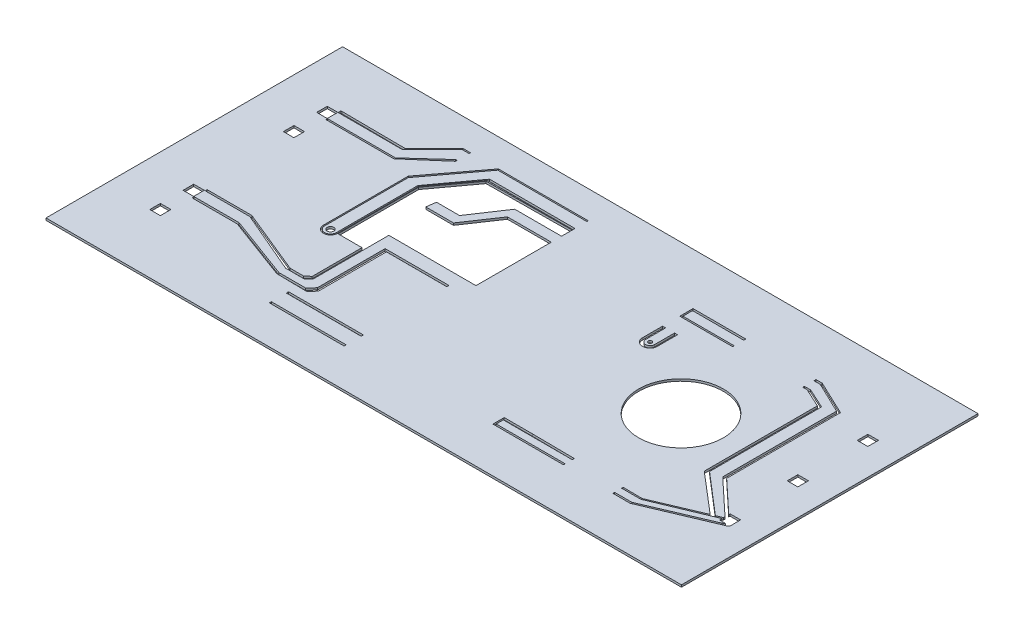
from build123d import *

# Parameters (mm, degrees)
SKETCH1_W           = 30
SKETCH1_H           = 14
SKETCH1_R           = 2
SKETCH1_R_2         = 0.156028334
SKETCH1_R_3         = 0.086225259
SKETCH1_W_2         = 0.499197809
SKETCH1_H_2         = 0.501456342
SKETCH1_H_3         = 0.501456343
SKETCH1_W_3         = 3.5304532
SKETCH1_H_4         = 0.096477131
BOSS_EXTRUDE2_DEPTH = 0.1


with BuildPart() as part:
    # Sketch1 → Boss-Extrude2 (new body)
    with BuildSketch(Plane(origin=(0, 0, 0), x_dir=(1, 0, 0), z_dir=(0, 1, 0))):
        with Locations((-15, 7)):
            Rectangle(SKETCH1_W, SKETCH1_H)
        with Locations((-7.020370045, 7)):
            Circle(SKETCH1_R, mode=Mode.SUBTRACT)
        with Locations((-22.822406344, 6.255391347)):
            Circle(SKETCH1_R_2, mode=Mode.SUBTRACT)
        with Locations((-10.66724947, 9.187062819)):
            Circle(SKETCH1_R_3, mode=Mode.SUBTRACT)
        with Locations((-1.506295526, 10.305773891)):
            Rectangle(SKETCH1_W_2, SKETCH1_H_2, mode=Mode.SUBTRACT)
        with Locations((-1.506058557, 7)):
            Rectangle(SKETCH1_W_2, SKETCH1_H_2, mode=Mode.SUBTRACT)
        Polygon((-1.256485692, 3.550454026), (-1.28140444, 3.550454026), (-1.335016171, 3.481213999), (-4.54690164, 2.121887432), (-5.360261371, 2.121887432), (-5.360261371, 2.203832458), (-4.54690164, 2.203832458), (-1.558352374, 3.481213999), (-1.472133003, 3.550454026), (-1.755683501, 3.550454026), (-1.755683501, 3.663429203), (-1.781688576, 3.652423397), (-4.453252976, 2.537894228), (-5.360261371, 2.537894228), (-5.360261371, 2.611390791), (-4.453252976, 2.602147786), (-2.199910697, 3.555801973), (-2.230986224, 3.58233105), (-4.109880419, 5.186336967), (-4.109880419, 10.52625285), (-5.01178132, 10.9436629), (-5.2151716, 10.9436629), (-5.2151716, 11.019115731), (-4.92219693, 11.019115731), (-3.967960979, 10.583630365), (-3.967960979, 5.294234739), (-2.054874003, 3.652423397), (-2.027101226, 3.628937988), (-1.781688576, 3.732800949), (-1.755683501, 3.743806755), (-1.755683501, 3.811781185), (-1.824138086, 3.875872934), (-3.440230513, 5.388966468), (-3.440230513, 10.76142511), (-4.92219693, 11.471832711), (-5.2151716, 11.471832711), (-5.2151716, 11.567863586), (-4.92219693, 11.567863586), (-3.286271687, 10.793793894), (-3.286271687, 5.420857378), (-1.824138086, 4.051910368), (-1.755683501, 3.987818619), (-1.755683501, 4.051910368), (-1.256485692, 4.051910368), align=None, mode=Mode.SUBTRACT)
        Polygon((-20.740691313, 3.555801973), (-20.740691313, 6.751171354), (-17.726140192, 6.751171354), (-17.726140192, 6.648804669), (-20.577135817, 6.648804669), (-20.577135817, 6.588691856), (-20.577135817, 3.434422851), (-20.839350262, 3.147232695), (-22.275377127, 3.170945708), (-25.245108692, 4.270018773), (-27.280489968, 4.270018773), (-27.371609442, 4.270018773), (-27.371609442, 4.36632395), (-27.280489968, 4.36632395), (-25.245108692, 4.36632395), (-22.268787234, 3.26481202), (-21.006375102, 3.26481202), align=None, mode=Mode.SUBTRACT)
        Polygon((-21.196743275, 7.250728171), (-21.196743275, 4.159991696), (-21.196743275, 3.801090583), (-21.398034662, 3.601705999), (-22.289698939, 3.601705999), (-25.245108692, 4.867780292), (-27.280489968, 4.867780292), (-27.350305288, 4.867780292), (-27.350305288, 4.960770533), (-27.280489968, 4.960770533), (-25.245108692, 4.960770533), (-22.177931991, 3.706985367), (-21.552803523, 3.706985367), (-21.32716444, 3.895195799), (-21.32716444, 6.24470924), (-22.461941115, 6.24470924), (-22.461941115, 10.05504572), (-21.11708673, 11.889354862), (-17.082611668, 11.926021935), (-17.082611668, 11.511053117), (-17.082611668, 11.422021861), (-17.122361985, 11.422021861), (-19.29309074, 11.422021861), (-20.335207519, 9.860770298), (-21.423827816, 9.860770298), (-21.486437697, 9.415587946), (-20.176259884, 9.415587946), (-19.152866511, 10.937472578), (-17.122361985, 10.937472578), (-17.082611668, 10.937472578), (-17.082611668, 10.879889975), (-17.082611668, 7.382432578), (-17.726140192, 7.382432578), (-20.577135817, 7.382432578), (-21.196743275, 7.382432578), align=None, mode=Mode.SUBTRACT)
        with Locations((-27.644321584, 3.044426332)):
            Rectangle(SKETCH1_W_2, SKETCH1_H_3, mode=Mode.SUBTRACT)
        with Locations((-27.644321584, 4.617052121)):
            Rectangle(SKETCH1_W_2, SKETCH1_H_2, mode=Mode.SUBTRACT)
        with Locations((-27.677861275, 9.382947879)):
            Rectangle(SKETCH1_W_2, SKETCH1_H_2, mode=Mode.SUBTRACT)
        with Locations((-27.677861275, 10.955573669)):
            Rectangle(SKETCH1_W_2, SKETCH1_H_3, mode=Mode.SUBTRACT)
        Polygon((-27.350305288, 11.20630184), (-24.391373084, 11.20630184), (-22.978434678, 12.619240246), (-22.649427056, 12.619240246), (-22.649427056, 12.684571648), (-23.000461853, 12.684571648), (-24.206065105, 11.478968396), (-24.365525074, 11.319508427), (-27.350305288, 11.342635118), (-27.41709617, 11.342635118), (-27.41709617, 11.20630184), align=None, mode=Mode.SUBTRACT)
        Polygon((-22.649427056, 12.055976166), (-22.721193305, 12.055976166), (-24.207502155, 10.704845497), (-27.350305288, 10.704845497), (-27.41709617, 10.704845497), (-27.41709617, 10.628998487), (-27.350305288, 10.628998487), (-24.207502155, 10.628998487), (-22.687589847, 11.947769263), (-22.649427056, 11.947769263), align=None, mode=Mode.SUBTRACT)
        Polygon((-21.256593392, 2.708605309), (-20.577135817, 2.708605309), (-17.726140192, 2.708605309), (-17.726140192, 2.602147786), (-20.577135817, 2.602147786), (-21.256593392, 2.602147786), align=None, mode=Mode.SUBTRACT)
        with Locations((-19.491366792, 1.848628129)):
            Rectangle(SKETCH1_W_3, SKETCH1_H_4, mode=Mode.SUBTRACT)
        with BuildLine():
            Line((-22.547722421, 9.635418098), (-22.547722421, 6.231004531))
            ThreePointArc((-22.547722421, 6.231004531), (-22.834611713, 5.979897239), (-23.09817069, 6.255391347))
            Line((-23.09817069, 6.255391347), (-23.09817069, 9.635418098))
            Line((-23.09817069, 9.635418098), (-23.09817069, 10.19716986))
            Line((-23.09817069, 10.19716986), (-21.285526409, 12.619240246))
            Line((-21.285526409, 12.619240246), (-17.082611668, 12.619240246))
            Line((-17.082611668, 12.619240246), (-17.082611668, 12.684571648))
            Line((-17.082611668, 12.684571648), (-21.32716444, 12.684571648))
            Line((-21.32716444, 12.684571648), (-23.158169226, 10.26019319))
            Line((-23.158169226, 10.26019319), (-23.158169226, 9.635418098))
            Line((-23.158169226, 9.635418098), (-23.158169226, 6.255391347))
            ThreePointArc((-23.158169226, 6.255391347), (-22.827748074, 5.91967096), (-22.486813428, 6.24470924))
            Line((-22.486813428, 6.24470924), (-22.486813428, 10.099242499))
            Line((-22.486813428, 10.099242499), (-21.11708673, 11.947769263))
            Line((-21.11708673, 11.947769263), (-17.082611668, 11.947769263))
            Line((-17.082611668, 11.947769263), (-17.082611668, 12.055976166))
            Line((-17.082611668, 12.055976166), (-21.11708673, 12.055976166))
            Line((-21.11708673, 12.055976166), (-22.547722421, 10.099242499))
            Line((-22.547722421, 10.099242499), (-22.547722421, 9.635418098))
        make_face(mode=Mode.SUBTRACT)
        Polygon((-9.676546893, 2.655376547), (-7.690286822, 2.635135266), (-7.690286822, 2.537894228), (-10.948813257, 2.537894228), (-10.948813257, 2.203832458), (-7.690286822, 2.203832458), (-7.690286822, 2.121887432), (-9.723371226, 2.121887432), (-11.022343809, 2.121887432), (-11.022343809, 2.655376547), align=None, mode=Mode.SUBTRACT)
        with BuildLine():
            Line((-11.022343809, 9.187062819), (-11.022343809, 10.13231451))
            Line((-11.022343809, 10.13231451), (-10.876593598, 10.13231451))
            Line((-10.876593598, 10.13231451), (-10.876593598, 9.187062819))
            ThreePointArc((-10.876593598, 9.187062819), (-10.66724947, 8.97771869), (-10.457905342, 9.187062819))
            Line((-10.457905342, 9.187062819), (-10.457905342, 10.13231451))
            Line((-10.457905342, 10.13231451), (-10.317570093, 10.13231451))
            Line((-10.317570093, 10.13231451), (-10.317570093, 9.125286422))
            ThreePointArc((-10.317570093, 9.125286422), (-10.698256102, 8.83332481), (-11.022343809, 9.187062819))
        make_face(mode=Mode.SUBTRACT)
        Polygon((-11.022343809, 11.567863586), (-8.527519195, 11.567863586), (-8.527519195, 11.471832711), (-8.617764349, 11.471832711), (-10.948813257, 11.471832711), (-10.948813257, 11.019115731), (-8.617764349, 11.019115731), (-8.527519195, 11.019115731), (-8.527519195, 10.9436629), (-11.022343809, 10.9436629), (-11.022343809, 11.266245402), align=None, mode=Mode.SUBTRACT)
    extrude(amount=BOSS_EXTRUDE2_DEPTH)


solid = part.part
